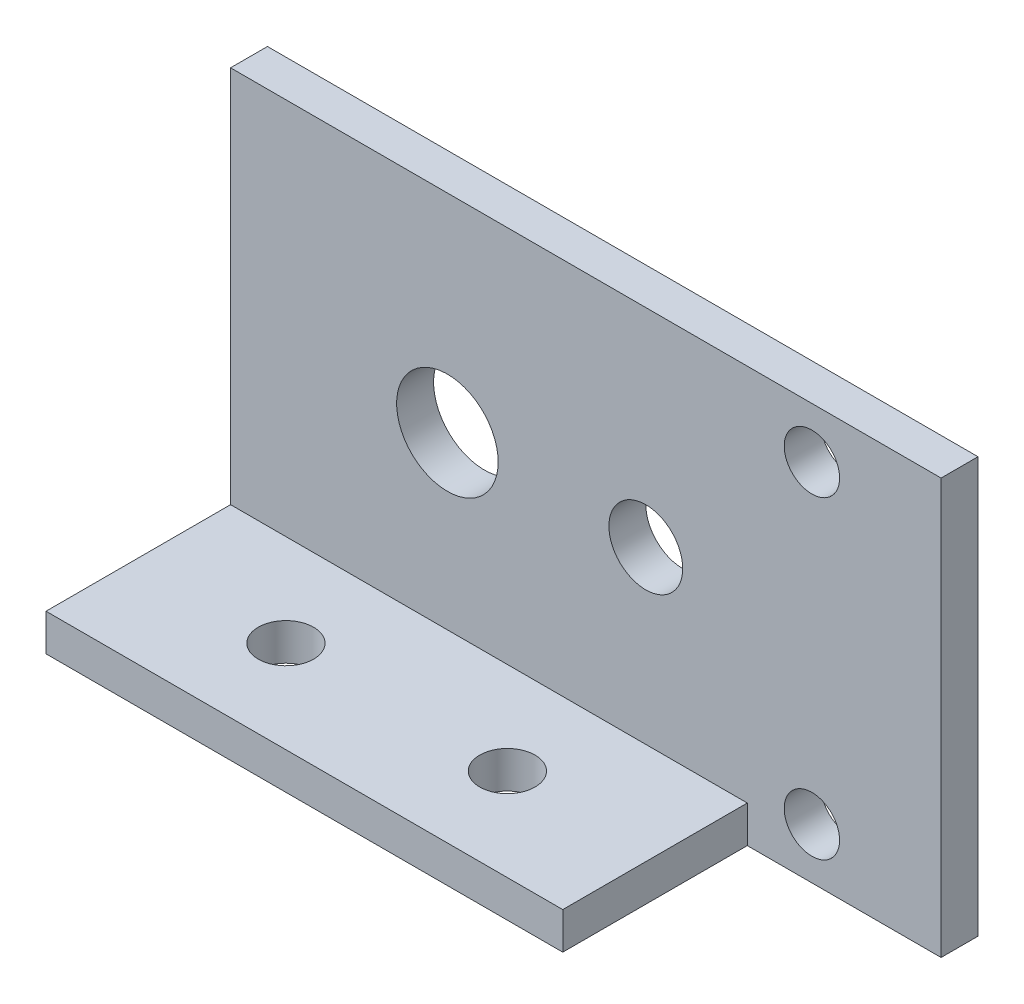
from build123d import *

# Parameters (mm, degrees)
SKETCH1_W           = 38.5
SKETCH1_H           = 22.5
SKETCH1_R           = 2.75
SKETCH1_R_2         = 2
SKETCH1_R_3         = 1.5
BOSS_EXTRUDE1_DEPTH = 2
SKETCH2_W           = 10
SKETCH2_H           = 2
BOSS_EXTRUDE2_DEPTH = 28
SKETCH4_R           = 1.5
CUT_EXTRUDE1_DEPTH  = 5


with BuildPart() as part:
    # Sketch1 → Boss-Extrude1 (new body)
    with BuildSketch(Plane.XY):
        Rectangle(SKETCH1_W, SKETCH1_H)
        with Locations((-7.5, 0)):
            Circle(SKETCH1_R, mode=Mode.SUBTRACT)
        with Locations((3.25, 0)):
            Circle(SKETCH1_R_2, mode=Mode.SUBTRACT)
        with Locations((12.25, -8.5)):
            Circle(SKETCH1_R_3, mode=Mode.SUBTRACT)
        with Locations((12.25, 8.5)):
            Circle(SKETCH1_R_3, mode=Mode.SUBTRACT)
    extrude(amount=BOSS_EXTRUDE1_DEPTH)

    # Sketch2 → Boss-Extrude2 (add)
    with BuildSketch(Plane.ZY.offset(19.25)):
        with Locations((7, -10.25)):
            Rectangle(SKETCH2_W, SKETCH2_H)
    extrude(amount=-BOSS_EXTRUDE2_DEPTH)

    # Sketch4 → Cut-Extrude1 (cut)
    with BuildSketch(Plane(origin=(0, -9.25, 0), x_dir=(1, 0, 0), z_dir=(0, 1, 0))):
        with Locations(Location((-11.25, -7, 0), (0, 0, 270))):  # turned: the seam where the file's is
            Circle(SKETCH4_R)
        with Locations(Location((0.75, -7, 0), (0, 0, 270))):  # turned: the seam where the file's is
            Circle(SKETCH4_R)
    extrude(amount=-CUT_EXTRUDE1_DEPTH, mode=Mode.SUBTRACT)


solid = part.part
